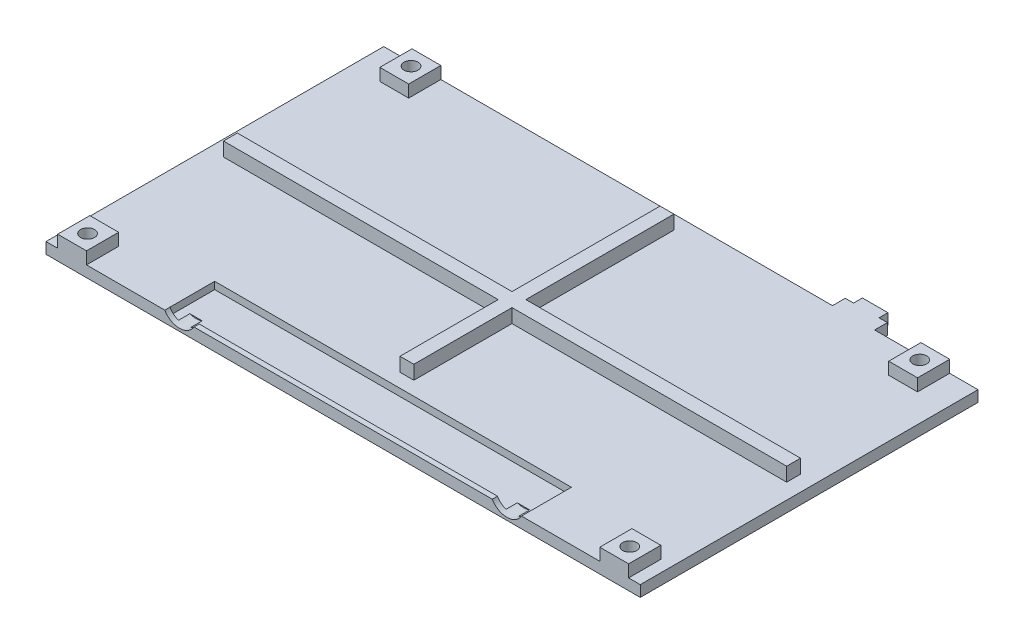
from build123d import *

# Parameters (mm, degrees)
SKETCH1_W            = 136.0932
SKETCH1_H            = 77.343
BOSS_EXTRUDE1_DEPTH  = 2.54
SKETCH2_R            = 3.8735
CUT_EXTRUDE1_DEPTH   = 3.81
SKETCH3_W            = 81.691378436
SKETCH3_H            = 10.2362
CUT_EXTRUDE2_DEPTH   = 1.651
SKETCH4_W            = 6.604
SKETCH4_H            = 7.366
BOSS_EXTRUDE4_DEPTH  = 2.794
SKETCH5_R            = 2.8575
CUT_EXTRUDE3_DEPTH   = 2.032
M3_CLEARANCE_HOLE1_D = 3.2
SKETCH9_W            = 9.652
SKETCH9_H            = 2.54
BOSS_EXTRUDE5_DEPTH  = 2.921
SKETCH10_W           = 5.842
SKETCH10_H           = 2.54
BOSS_EXTRUDE6_DEPTH  = 2.032
BOSS_EXTRUDE7_DEPTH  = 3.175


with BuildPart() as part:
    # Sketch1 → Boss-Extrude1 (new body)
    with BuildSketch(Plane(origin=(0, 0, 0), x_dir=(1, 0, 0), z_dir=(0, 1, 0))):
        with Locations((68.0466, 38.6715)):
            Rectangle(SKETCH1_W, SKETCH1_H)
    extrude(amount=BOSS_EXTRUDE1_DEPTH)

    # Sketch2 → Cut-Extrude1 (cut)
    with BuildSketch(Plane.XY):
        with Locations((105.5477, 4.4939)):
            Circle(SKETCH2_R)
        with Locations((30.5455, 4.4939)):
            Circle(SKETCH2_R)
    extrude(amount=-CUT_EXTRUDE1_DEPTH, mode=Mode.SUBTRACT)

    # Sketch3 → Cut-Extrude2 (cut)
    with BuildSketch(Plane(origin=(0, 2.54, 0), x_dir=(1, 0, 0), z_dir=(0, 1, 0))):
        with Locations((68.0466, 6.3119)):
            Rectangle(SKETCH3_W, SKETCH3_H)
    extrude(amount=-CUT_EXTRUDE2_DEPTH, mode=Mode.SUBTRACT)

    # Sketch4 → Boss-Extrude4 (add)
    with BuildSketch(Plane(origin=(0, 2.54, 0), x_dir=(1, 0, 0), z_dir=(0, 1, 0))):
        with Locations((130.1242, 3.683)):
            Rectangle(SKETCH4_W, SKETCH4_H)
        with Locations((5.969, 3.683)):
            Rectangle(SKETCH4_W, SKETCH4_H)
        with Locations((126.3142, 73.66)):
            Rectangle(SKETCH4_W, SKETCH4_H)
        with Locations((9.779, 73.66)):
            Rectangle(SKETCH4_W, SKETCH4_H)
    extrude(amount=BOSS_EXTRUDE4_DEPTH)

    # Sketch5 → Cut-Extrude3 (cut)
    with BuildSketch(Plane(origin=(0, 0, 0), x_dir=(-1, 0, 0), z_dir=(0, -1, 0))):
        with Locations((-126.3142, 73.787)):
            Circle(SKETCH5_R)
        with Locations((-9.8044, 73.787)):
            Circle(SKETCH5_R)
        with Locations((-5.969, 3.556)):
            Circle(SKETCH5_R)
        with Locations((-130.1242, 3.556)):
            Circle(SKETCH5_R)
    extrude(amount=-CUT_EXTRUDE3_DEPTH, mode=Mode.SUBTRACT)

    # M3 Clearance Hole1 (through all)
    with Locations(Plane(origin=(0, 2.032, 0), x_dir=(-1, 0, 0), z_dir=(0, -1, 0))):
        with Locations((-5.969, 3.556), (-130.1242, 3.556), (-126.3142, 73.787), (-9.8044, 73.787)):
            Hole(M3_CLEARANCE_HOLE1_D / 2)

    # Sketch9 → Boss-Extrude5 (add)
    with BuildSketch(Plane(origin=(0, 0, -77.343), x_dir=(-1, 0, 0), z_dir=(0, 0, -1))):
        with Locations((-107.5944, 1.27)):
            Rectangle(SKETCH9_W, SKETCH9_H)
    extrude(amount=BOSS_EXTRUDE5_DEPTH)

    # Sketch10 → Boss-Extrude6 (add)
    with BuildSketch(Plane(origin=(0, 0, -80.264), x_dir=(-1, 0, 0), z_dir=(0, 0, -1))):
        with Locations((-107.5944, 1.27)):
            Rectangle(SKETCH10_W, SKETCH10_H)
    extrude(amount=BOSS_EXTRUDE6_DEPTH)

    # Sketch11 → Boss-Extrude7 (add)
    with BuildSketch(Plane(origin=(0, 2.54, 0), x_dir=(1, 0, 0), z_dir=(0, 1, 0))):
        Polygon((132.5372, 37.084), (69.6341, 37.084), (69.6341, 14.605), (66.4591, 14.605), (66.4591, 37.084), (3.556, 37.084), (3.556, 40.259), (66.4591, 40.259), (66.4591, 74.168), (69.6341, 74.168), (69.6341, 40.259), (132.5372, 40.259), align=None)
    extrude(amount=BOSS_EXTRUDE7_DEPTH)


solid = part.part
